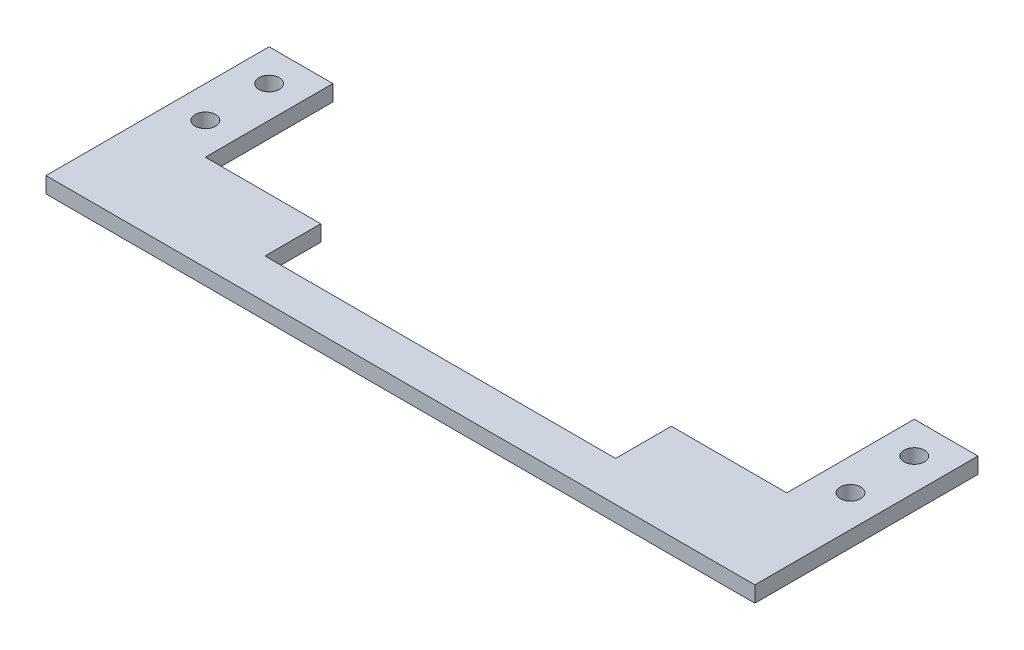
from build123d import *

# Parameters (mm, degrees)
SKETCH1_R           = 2.032
BOSS_EXTRUDE1_DEPTH = 3.175


with BuildPart() as part:
    # Sketch1 → Boss-Extrude1 (new body)
    with BuildSketch(Plane(origin=(0, 0, 0), x_dir=(1, 0, 0), z_dir=(0, 1, 0))):
        Polygon((105.537, 19.05), (128.524, 19.05), (128.524, 44.45), (141.224, 44.45), (141.224, 0), (0, 0), (0, 44.45), (12.7, 44.45), (12.7, 19.05), (35.687, 19.05), (35.687, 7.9375), (105.537, 7.9375), align=None)
        with Locations((134.874, 38.1)):
            Circle(SKETCH1_R, mode=Mode.SUBTRACT)
        with Locations((6.35, 25.4)):
            Circle(SKETCH1_R, mode=Mode.SUBTRACT)
        with Locations((6.35, 38.1)):
            Circle(SKETCH1_R, mode=Mode.SUBTRACT)
        with Locations((134.874, 25.4)):
            Circle(SKETCH1_R, mode=Mode.SUBTRACT)
    extrude(amount=BOSS_EXTRUDE1_DEPTH)


solid = part.part
